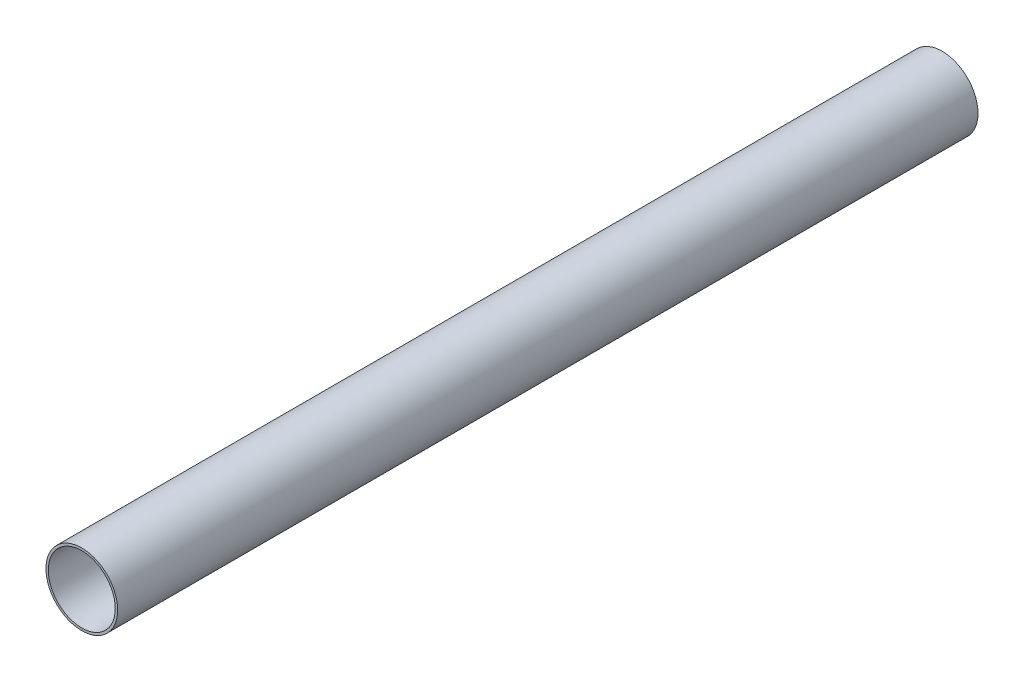
from build123d import *

# Parameters (mm, degrees)
PIPESKETCH_R    = 228.6
PIPESKETCH_R_2  = 213.5124
EXTRUSION_DEPTH = 5486.4


with BuildPart() as part:
    # PipeSketch → Extrusion (new body)
    with BuildSketch(Plane.XY):
        Circle(PIPESKETCH_R)
        Circle(PIPESKETCH_R_2, mode=Mode.SUBTRACT)
    extrude(amount=EXTRUSION_DEPTH)


solid = part.part
